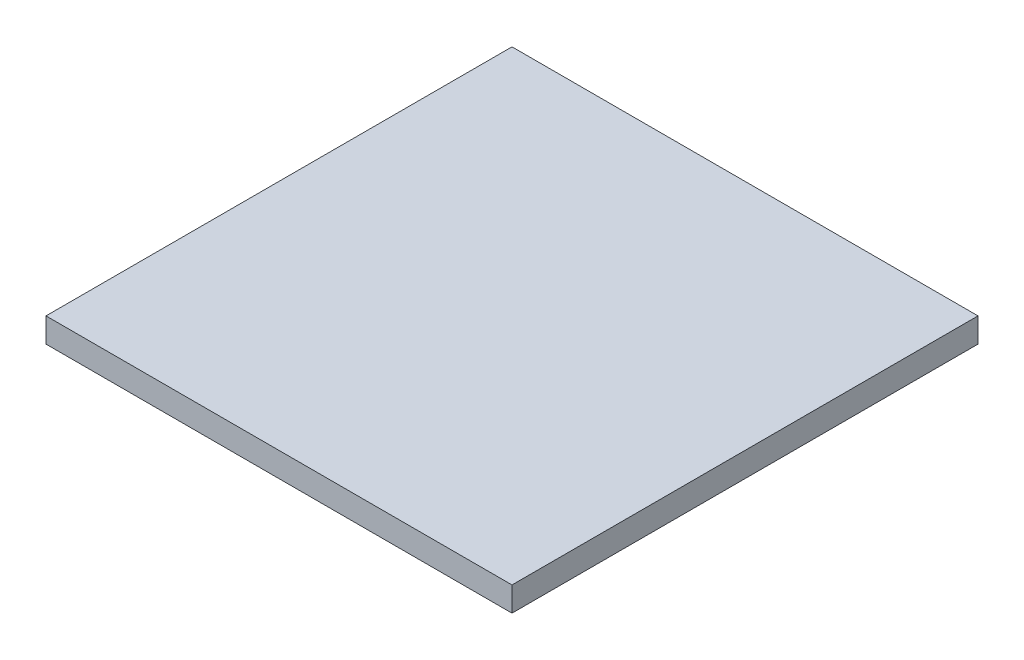
from build123d import *

# Parameters (mm, degrees)
SKETCH2_W           = 10
SKETCH2_H           = 10
BOSS_EXTRUDE1_DEPTH = 0.525


with BuildPart() as part:
    # Sketch2 → Boss-Extrude1 (new body)
    with BuildSketch(Plane(origin=(0, 0, 0), x_dir=(1, 0, 0), z_dir=(0, 1, 0))):
        Rectangle(SKETCH2_W, SKETCH2_H)
    extrude(amount=BOSS_EXTRUDE1_DEPTH)


solid = part.part
